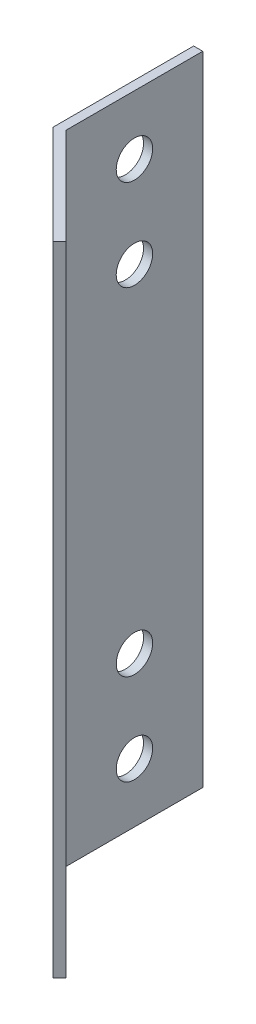
from build123d import *

# Parameters (mm, degrees)
EXTRUSION1_DEPTH = 70
EXTRUSION2_REACH = 3
ESQUISSE2_R      = 2
EXTRUSION3_REACH = 10.707
ESQUISSE3_R      = 2


with BuildPart() as part:
    # Esquisse1 → Extrusion1 (new body)
    with BuildSketch(Plane(origin=(0, 0, 0), x_dir=(1, 0, 0), z_dir=(0, 1, 0))):
        Polygon((0, 0), (0, 15.414213562), (1, 15.414213562), (1, 0.414213562), (11.606601718, -10.192388155), (10.899494937, -10.899494937), align=None)
    extrude(amount=EXTRUSION1_DEPTH)

    # Esquisse2 → Extrusion2 (cut, up to next)
    with BuildSketch(Plane(origin=(1, 0, 0), x_dir=(0, 0, -1), z_dir=(1, 0, 0)), mode=Mode.PRIVATE) as extrusion2_sk1:
        with Locations((7.914213562, 16.5)):
            Circle(ESQUISSE2_R)
    extrusion2_tool1 = extrude(extrusion2_sk1.sketch, amount=-EXTRUSION2_REACH, mode=Mode.PRIVATE) & part.part
    add(extrusion2_tool1.solids().sort_by_distance((1, 16.5, -7.914214))[0], mode=Mode.SUBTRACT)
    # Esquisse2 → Extrusion2 (cut, up to next)
    with BuildSketch(Plane(origin=(1, 0, 0), x_dir=(0, 0, -1), z_dir=(1, 0, 0)), mode=Mode.PRIVATE) as extrusion2_sk2:
        with Locations((7.914213562, 6.5)):
            Circle(ESQUISSE2_R)
    extrusion2_tool2 = extrude(extrusion2_sk2.sketch, amount=-EXTRUSION2_REACH, mode=Mode.PRIVATE) & part.part
    add(extrusion2_tool2.solids().sort_by_distance((1, 6.5, -7.914214))[0], mode=Mode.SUBTRACT)
    # Esquisse2 → Extrusion2 (cut, up to next)
    with BuildSketch(Plane(origin=(1, 0, 0), x_dir=(0, 0, -1), z_dir=(1, 0, 0)), mode=Mode.PRIVATE) as extrusion2_sk3:
        with Locations((7.914213562, 53.5)):
            Circle(ESQUISSE2_R)
    extrusion2_tool3 = extrude(extrusion2_sk3.sketch, amount=-EXTRUSION2_REACH, mode=Mode.PRIVATE) & part.part
    add(extrusion2_tool3.solids().sort_by_distance((1, 53.5, -7.914214))[0], mode=Mode.SUBTRACT)
    # Esquisse2 → Extrusion2 (cut, up to next)
    with BuildSketch(Plane(origin=(1, 0, 0), x_dir=(0, 0, -1), z_dir=(1, 0, 0)), mode=Mode.PRIVATE) as extrusion2_sk4:
        with Locations((7.914213562, 63.5)):
            Circle(ESQUISSE2_R)
    extrusion2_tool4 = extrude(extrusion2_sk4.sketch, amount=-EXTRUSION2_REACH, mode=Mode.PRIVATE) & part.part
    add(extrusion2_tool4.solids().sort_by_distance((1, 63.5, -7.914214))[0], mode=Mode.SUBTRACT)

    # Esquisse3 → Extrusion3 (cut, up to next)
    with BuildSketch(Plane(origin=(0.707106781, 0, -0.707106781), x_dir=(-0.707106781, 0, -0.707106781), z_dir=(0.707106781, 0, -0.707106781)), mode=Mode.PRIVATE) as extrusion3_sk1:
        with Locations((-7.914213562, 53.5)):
            Circle(ESQUISSE3_R)
    extrusion3_tool1 = extrude(extrusion3_sk1.sketch, amount=-EXTRUSION3_REACH, mode=Mode.PRIVATE) & part.part
    add(extrusion3_tool1.solids().sort_by_distance((6.303301, 53.5, 4.889087))[0], mode=Mode.SUBTRACT)
    # Esquisse3 → Extrusion3 (cut, up to next)
    with BuildSketch(Plane(origin=(0.707106781, 0, -0.707106781), x_dir=(-0.707106781, 0, -0.707106781), z_dir=(0.707106781, 0, -0.707106781)), mode=Mode.PRIVATE) as extrusion3_sk2:
        with Locations((-7.914213562, 63.5)):
            Circle(ESQUISSE3_R)
    extrusion3_tool2 = extrude(extrusion3_sk2.sketch, amount=-EXTRUSION3_REACH, mode=Mode.PRIVATE) & part.part
    add(extrusion3_tool2.solids().sort_by_distance((6.303301, 63.5, 4.889087))[0], mode=Mode.SUBTRACT)
    # Esquisse3 → Extrusion3 (cut, up to next)
    with BuildSketch(Plane(origin=(0.707106781, 0, -0.707106781), x_dir=(-0.707106781, 0, -0.707106781), z_dir=(0.707106781, 0, -0.707106781)), mode=Mode.PRIVATE) as extrusion3_sk3:
        with Locations((-7.914213562, 6.5)):
            Circle(ESQUISSE3_R)
    extrusion3_tool3 = extrude(extrusion3_sk3.sketch, amount=-EXTRUSION3_REACH, mode=Mode.PRIVATE) & part.part
    add(extrusion3_tool3.solids().sort_by_distance((6.303301, 6.5, 4.889087))[0], mode=Mode.SUBTRACT)
    # Esquisse3 → Extrusion3 (cut, up to next)
    with BuildSketch(Plane(origin=(0.707106781, 0, -0.707106781), x_dir=(-0.707106781, 0, -0.707106781), z_dir=(0.707106781, 0, -0.707106781)), mode=Mode.PRIVATE) as extrusion3_sk4:
        with Locations((-7.914213562, 16.5)):
            Circle(ESQUISSE3_R)
    extrusion3_tool4 = extrude(extrusion3_sk4.sketch, amount=-EXTRUSION3_REACH, mode=Mode.PRIVATE) & part.part
    add(extrusion3_tool4.solids().sort_by_distance((6.303301, 16.5, 4.889087))[0], mode=Mode.SUBTRACT)


solid = part.part
